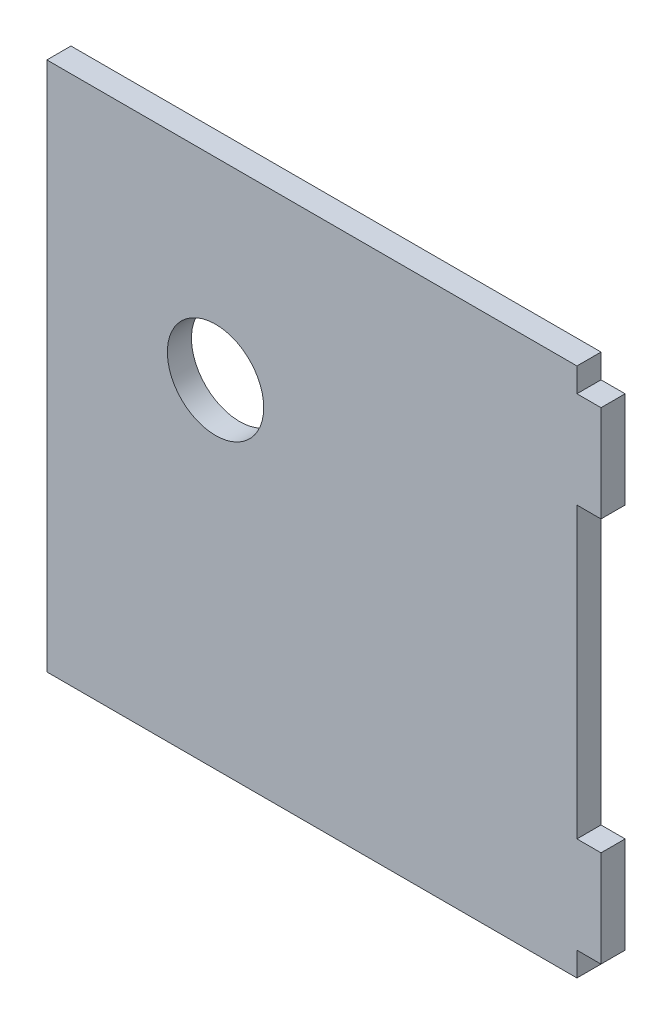
from build123d import *

# Parameters (mm, degrees)
SKETCH1_R           = 12.7
BOSS_EXTRUDE1_DEPTH = 6.35


with BuildPart() as part:
    # Sketch1 → Boss-Extrude1 (new body)
    with BuildSketch(Plane.XY):
        Polygon((139.7, 133.35), (146.05, 133.35), (146.05, 107.95), (139.7, 107.95), (139.7, 31.75), (146.05, 31.75), (146.05, 6.35), (139.7, 6.35), (139.7, 0), (0, 0), (0, 139.7), (139.7, 139.7), align=None)
        with Locations((44.45, 88.9)):
            Circle(SKETCH1_R, mode=Mode.SUBTRACT)
    extrude(amount=BOSS_EXTRUDE1_DEPTH)


solid = part.part
